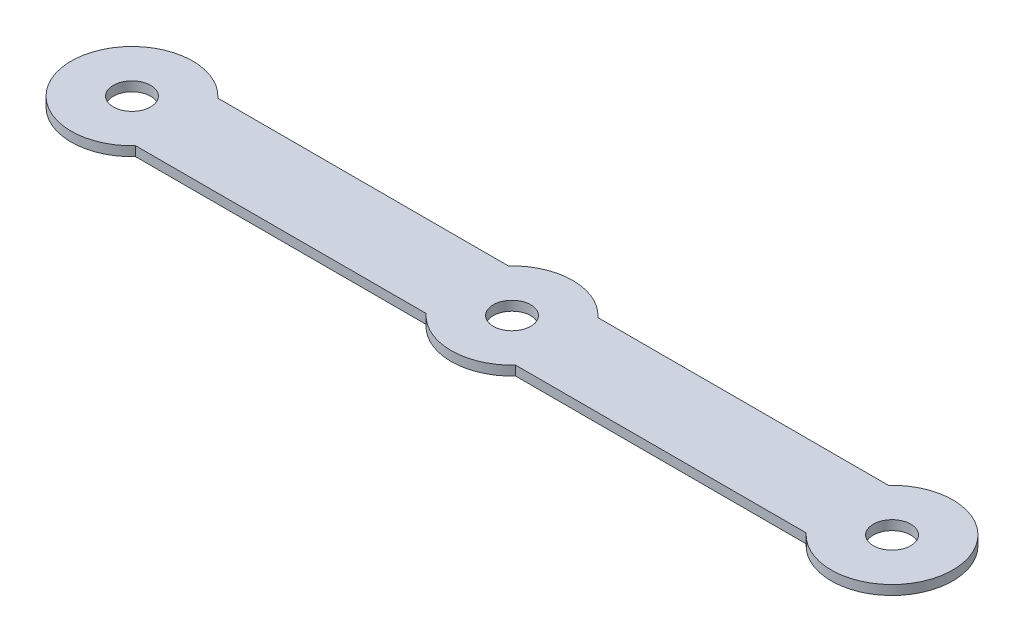
from build123d import *

# Parameters (mm, degrees)
BOSS_EXTRUDE1_DEPTH     = 2.54
SKETCH2_R               = 5
CUT_EXTRUDE1_DEPTH      = 1
CUT_EXTRUDE1_DEPTH_BACK = 3.54


with BuildPart() as part:
    # Sketch1 → Boss-Extrude1 (new body)
    with BuildSketch(Plane(origin=(0, 0, 0), x_dir=(1, 0, 0), z_dir=(0, 1, 0))):
        with BuildLine():
            Line((-89.636017598, 11), (-11.963982402, 11))
            ThreePointArc((-11.963982402, 11), (0, 16.252288298), (11.963982402, 11))
            Line((11.963982402, 11), (89.636017598, 11))
            ThreePointArc((89.636017598, 11), (117.852288298, 0), (89.636017598, -11))
            Line((89.636017598, -11), (11.963982402, -11))
            ThreePointArc((11.963982402, -11), (0, -16.252288298), (-11.963982402, -11))
            Line((-11.963982402, -11), (-89.636017598, -11))
            ThreePointArc((-89.636017598, -11), (-117.852288298, 0), (-89.636017598, 11))
        make_face()
    extrude(amount=BOSS_EXTRUDE1_DEPTH)

    # Sketch2 → Cut-Extrude1 (cut, two sides)
    with BuildSketch(Plane(origin=(0, 2.54, 0), x_dir=(1, 0, 0), z_dir=(0, 1, 0))) as cut_extrude1_sk:
        with Locations((-101.6, 0)):
            Circle(SKETCH2_R)
        with Locations((101.6, 0)):
            Circle(SKETCH2_R)
        Circle(SKETCH2_R)
    extrude(amount=CUT_EXTRUDE1_DEPTH, mode=Mode.SUBTRACT)
    extrude(cut_extrude1_sk.sketch, amount=-CUT_EXTRUDE1_DEPTH_BACK, mode=Mode.SUBTRACT)


solid = part.part
